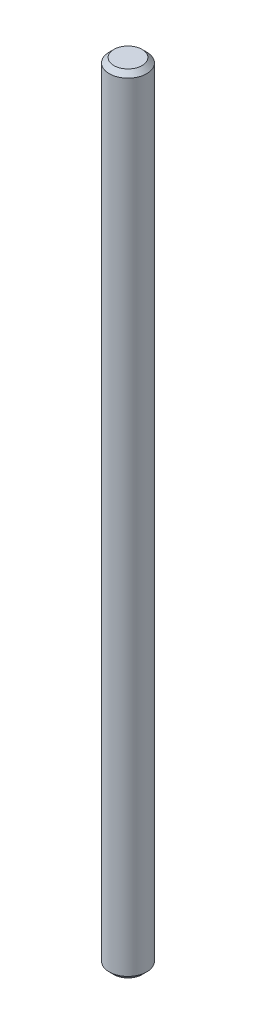
from build123d import *

# Parameters (mm, degrees)
SKETCH2_R           = 2
BOSS_EXTRUDE1_DEPTH = 84
CHAMFER1_SIZE       = 0.5


with BuildPart() as part:
    # Sketch2 → Boss-Extrude1 (new body)
    with BuildSketch(Plane(origin=(0, 0, 0), x_dir=(1, 0, 0), z_dir=(0, 1, 0))):
        Circle(SKETCH2_R)
    extrude(amount=BOSS_EXTRUDE1_DEPTH)

    # Chamfer1
    chamfer1_edges = [part.edges().sort_by_distance(p)[0] for p in [
        (-2, 0, 0),
        (-2, 84, 0),
    ]]
    chamfer(chamfer1_edges, length=CHAMFER1_SIZE)


solid = part.part
